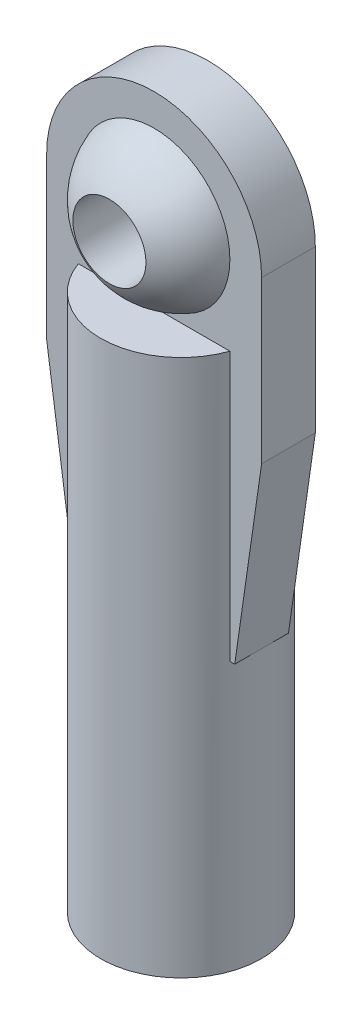
from build123d import *

# Parameters (mm, degrees)
SKETCH3_R                 = 1.0795
CUT_EXTRUDE1_DEPTH        = 3.3749
CUT_EXTRUDE1_DEPTH_BACK   = 3.3749
SKETCH4_R                 = 1.0795
BOSS_EXTRUDE1_DEPTH       = 0.79375
SKETCH5_R                 = 2.3749
BOSS_EXTRUDE2_DEPTH       = 7.9375
F_4_40_TAPPED_HOLE1_D     = 2.2606
F_4_40_TAPPED_HOLE1_DEPTH = 12.7
F_4_40_TAPPED_HOLE1_TIP   = 0.679152758


with BuildPart() as part:
    # Sketch2 → Revolve1 (revolve)
    with BuildSketch(Plane.XY):
        with BuildLine():
            Line((0, 2.3749), (0, -2.3749))
            ThreePointArc((0, -2.3749), (2.3749, 0), (0, 2.3749))
        make_face()
    revolve(axis=Axis((0, 6.043929029, 0), (0, -1, 0)))

    # Sketch3 → Cut-Extrude1 (cut, two sides)
    with BuildSketch(Plane.XY) as cut_extrude1_sk:
        Circle(SKETCH3_R)
    extrude(amount=CUT_EXTRUDE1_DEPTH, mode=Mode.SUBTRACT)
    extrude(cut_extrude1_sk.sketch, amount=-CUT_EXTRUDE1_DEPTH_BACK, mode=Mode.SUBTRACT)

    # Sketch4 → Boss-Extrude1 (add, symmetric)
    with BuildSketch(Plane.XY):
        with BuildLine():
            Line((-3.175, 0), (-3.175, -4.7625))
            Line((-3.175, -4.7625), (-2.38125, -10.287))
            Line((-2.38125, -10.287), (2.38125, -10.287))
            Line((2.38125, -10.287), (3.175, -4.7625))
            Line((3.175, -4.7625), (3.175, 0))
            ThreePointArc((3.175, 0), (0, 3.175), (-3.175, 0))
        make_face()
        Circle(SKETCH4_R, mode=Mode.SUBTRACT)
    extrude(amount=BOSS_EXTRUDE1_DEPTH, both=True)

    # Sketch5 → Boss-Extrude2 (add, symmetric)
    with BuildSketch(Plane.XZ.offset(10.287)):
        Circle(SKETCH5_R)
    extrude(amount=BOSS_EXTRUDE2_DEPTH, both=True)

    # #4-40 Tapped Hole1
    with Locations(Plane(origin=(0, -18.2245, 0), x_dir=(-1, 0, 0), z_dir=(0, -1, 0))):
        with Locations((0, 0)):
            Hole(F_4_40_TAPPED_HOLE1_D / 2, depth=F_4_40_TAPPED_HOLE1_DEPTH)
            with Locations((0, 0, -(F_4_40_TAPPED_HOLE1_DEPTH + F_4_40_TAPPED_HOLE1_TIP / 2))):  # 118° drill point
                Cone(0, F_4_40_TAPPED_HOLE1_D / 2, F_4_40_TAPPED_HOLE1_TIP, mode=Mode.SUBTRACT)


solid = part.part
